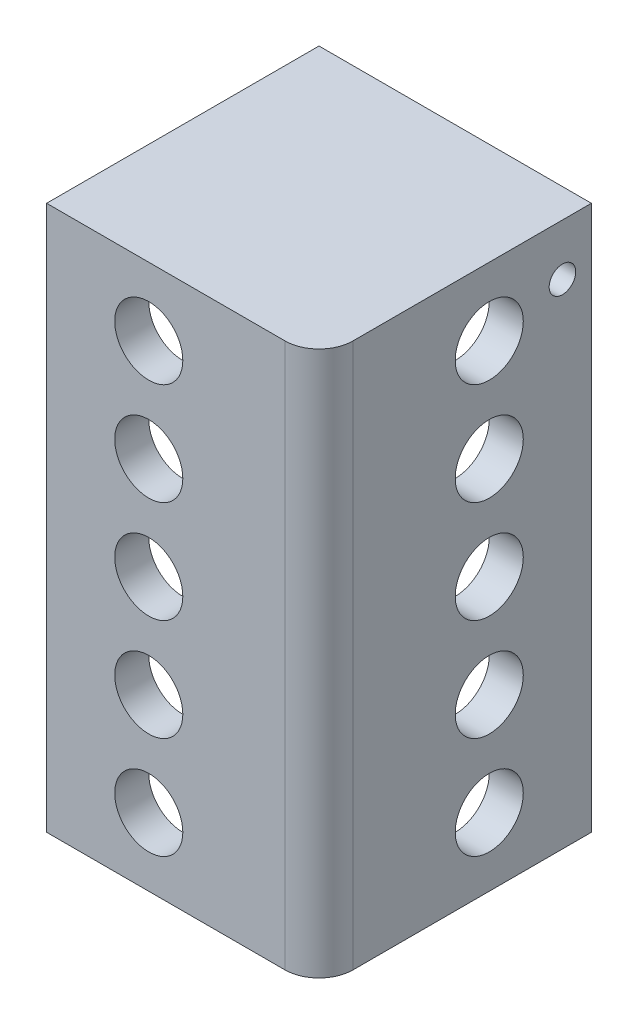
from build123d import *

# Parameters (mm, degrees)
SKETCH2_W           = 101.6
SKETCH2_H           = 101.6
BOSS_EXTRUDE1_DEPTH = 203.2
SKETCH4_W           = 88.9
SKETCH4_H           = 88.9
CUT_EXTRUDE1_DEPTH  = 95.25
FILLET1_R           = 12.7
SKETCH5_R           = 12.7
CUT_EXTRUDE2_DEPTH  = 102.6
SKETCH6_R           = 12.7
CUT_EXTRUDE3_DEPTH  = 102.6
CUT_EXTRUDE4_DEPTH  = 7.35
SKETCH31_W          = 8.89
SKETCH31_H          = 22.86
BOSS_EXTRUDE2_DEPTH = 25.4
FILLET2_R           = 6.35
FILLET3_R           = 12.7
SKETCH32_R          = 4.953
CUT_EXTRUDE5_DEPTH  = 53.578


with BuildPart() as part:
    # Sketch2 → Boss-Extrude1 (new body)
    with BuildSketch(Plane(origin=(0, 0, 0), x_dir=(1, 0, 0), z_dir=(0, 1, 0))):
        with Locations((9.448577681, 25.677899344)):
            Rectangle(SKETCH2_W, SKETCH2_H)
    extrude(amount=BOSS_EXTRUDE1_DEPTH)

    # Sketch4 → Cut-Extrude1 (cut, symmetric)
    with BuildSketch(Plane(origin=(0, 101.6, 0), x_dir=(1, 0, 0), z_dir=(0, 1, 0))):
        with Locations((3.098577681, 32.027899344)):
            Rectangle(SKETCH4_W, SKETCH4_H)
    extrude(amount=CUT_EXTRUDE1_DEPTH, both=True, mode=Mode.SUBTRACT)

    # Fillet1
    fillet1_edges = [part.edges().sort_by_distance(p)[0] for p in [
        (47.548577681, 101.6, 12.422100656),
        (60.248577681, 101.6, 25.122100656),
    ]]
    fillet(fillet1_edges, radius=FILLET1_R)

    # Sketch5 → Cut-Extrude2 (cut, through all)
    with BuildSketch(Plane.XY.offset(25.122100656)):
        with Locations((-3.251422319, 177.8)):
            Circle(SKETCH5_R)
        with Locations((-3.251422319, 139.7)):
            Circle(SKETCH5_R)
        with Locations((-3.251422319, 101.6)):
            Circle(SKETCH5_R)
        with Locations((-3.251422319, 63.5)):
            Circle(SKETCH5_R)
        with Locations((-3.251422319, 25.4)):
            Circle(SKETCH5_R)
    extrude(amount=-CUT_EXTRUDE2_DEPTH, mode=Mode.SUBTRACT)

    # Sketch6 → Cut-Extrude3 (cut, through all)
    with BuildSketch(Plane(origin=(60.248577681, 0, 0), x_dir=(0, 0, -1), z_dir=(1, 0, 0))):
        with Locations((38.377899344, 177.8)):
            Circle(SKETCH6_R)
        with Locations((38.377899344, 139.7)):
            Circle(SKETCH6_R)
        with Locations((38.377899344, 101.6)):
            Circle(SKETCH6_R)
        with Locations((38.377899344, 63.5)):
            Circle(SKETCH6_R)
        with Locations((38.377899344, 25.4)):
            Circle(SKETCH6_R)
    extrude(amount=-CUT_EXTRUDE3_DEPTH, mode=Mode.SUBTRACT)

    # Sketch7 → Cut-Extrude4 (cut, through all)
    with BuildSketch(Plane(origin=(0, 6.35, 0), x_dir=(1, 0, 0), z_dir=(0, 1, 0))):
        with BuildLine():
            Line((-41.351422319, 76.477899344), (47.548577681, 76.477899344))
            Line((47.548577681, 76.477899344), (47.548577681, 0.277899344))
            ThreePointArc((47.548577681, 0.277899344), (43.828833802, -8.702356778), (34.848577681, -12.422100656))
            Line((34.848577681, -12.422100656), (-41.351422319, -12.422100656))
            Line((-41.351422319, -12.422100656), (-41.351422319, 76.477899344))
        make_face()
    extrude(amount=-CUT_EXTRUDE4_DEPTH, mode=Mode.SUBTRACT)

    # Sketch31 → Boss-Extrude2 (add)
    with BuildSketch(Plane.XZ.offset(-196.85)):
        with Locations((12.115577681, -65.047899344)):
            Rectangle(SKETCH31_W, SKETCH31_H)
        with Locations((32.943577681, -65.047899344)):
            Rectangle(SKETCH31_W, SKETCH31_H)
    extrude(amount=BOSS_EXTRUDE2_DEPTH)

    # Fillet2
    fillet2_edges = [part.edges().sort_by_distance(p)[0] for p in [
        (12.115577681, 171.45, -53.617899344),
        (32.943577681, 171.45, -53.617899344),
    ]]
    fillet(fillet2_edges, radius=FILLET2_R)

    # Fillet3
    fillet3_edges = [part.edges().sort_by_distance(p)[0] for p in [
        (12.115577681, 171.45, -76.477899344),
        (32.943577681, 171.45, -76.477899344),
    ]]
    fillet(fillet3_edges, radius=FILLET3_R)

    # Sketch32 → Cut-Extrude5 (cut, through all)
    with BuildSketch(Plane.ZY.offset(-7.670577681)):
        with Locations((-65.682899344, 184.023)):
            Circle(SKETCH32_R)
    extrude(amount=-CUT_EXTRUDE5_DEPTH, mode=Mode.SUBTRACT)


solid = part.part
